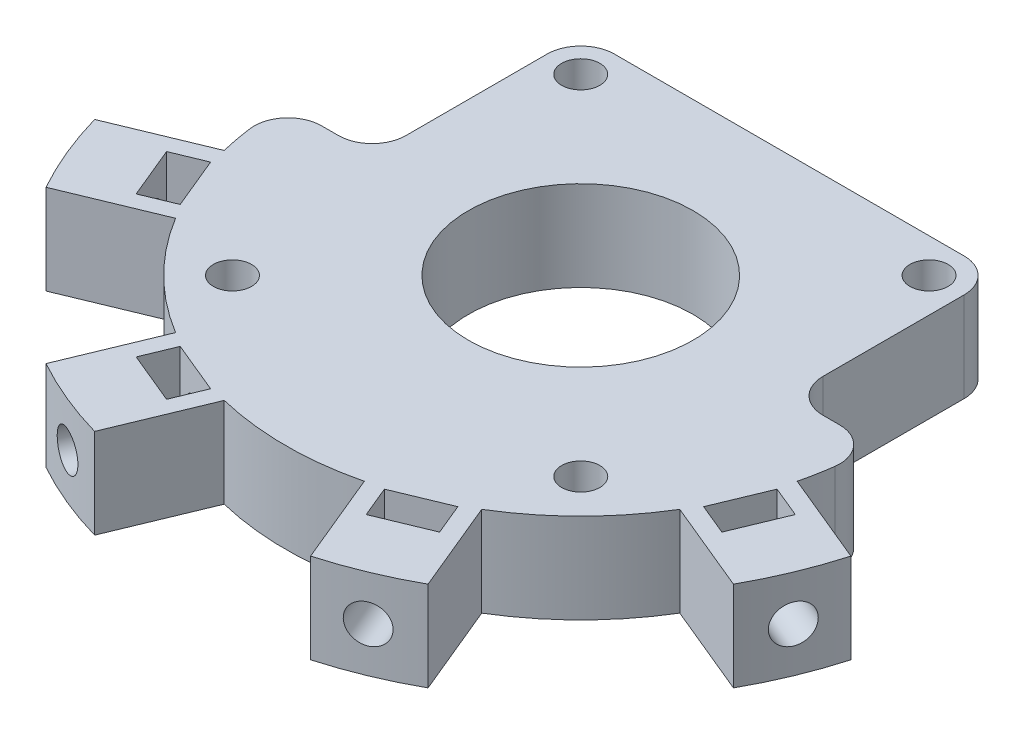
from build123d import *

# Parameters (mm, degrees)
SALIENTE_EXTRUIR1_DEPTH = 8
CROQUIS3_R              = 1.7
CORTAR_EXTRUIR1_DEPTH   = 10
CORTAR_EXTRUIR2_DEPTH   = 7
MATRIZC1_COUNT          = 4
MATRIZC1_ANGLE          = 135
CROQUIS5_R              = 10
CROQUIS5_R_2            = 1.7
CORTAR_EXTRUIR3_DEPTH   = 8
CORTAR_EXTRUIR4_DEPTH   = 8
REDONDEO1_R             = 3


with BuildPart() as part:
    # Croquis1 → Saliente-Extruir1 (new body)
    with BuildSketch(Plane(origin=(0, 0, 0), x_dir=(1, 0, 0), z_dir=(0, 1, 0))):
        with BuildLine():
            Line((-33.65465082, -9.610644005), (-25.499354444, -6.232609641))
            ThreePointArc((-25.499354444, -6.232609641), (0, 26.25), (25.499354444, -6.232609641))
            Line((25.499354444, -6.232609641), (33.65465082, -9.610644005))
            ThreePointArc((33.65465082, -9.610644005), (32.335783638, -13.393920133), (30.593183361, -17.001680265))
            Line((30.593183361, -17.001680265), (22.437886985, -13.623645901))
            ThreePointArc((22.437886985, -13.623645901), (18.561553006, -18.561553006), (13.623645901, -22.437886985))
            Line((13.623645901, -22.437886985), (17.001680265, -30.593183361))
            ThreePointArc((17.001680265, -30.593183361), (13.393920133, -32.335783638), (9.610644005, -33.65465082))
            Line((9.610644005, -33.65465082), (6.232609641, -25.499354444))
            ThreePointArc((6.232609641, -25.499354444), (0, -26.25), (-6.232609641, -25.499354444))
            Line((-6.232609641, -25.499354444), (-9.610644005, -33.65465082))
            ThreePointArc((-9.610644005, -33.65465082), (-13.393920133, -32.335783638), (-17.001680265, -30.593183361))
            Line((-17.001680265, -30.593183361), (-13.623645901, -22.437886985))
            ThreePointArc((-13.623645901, -22.437886985), (-18.561553006, -18.561553006), (-22.437886985, -13.623645901))
            Line((-22.437886985, -13.623645901), (-30.593183361, -17.001680265))
            ThreePointArc((-30.593183361, -17.001680265), (-32.335783638, -13.393920133), (-33.65465082, -9.610644005))
        make_face()
    extrude(amount=SALIENTE_EXTRUIR1_DEPTH)

    # Croquis3 → Cortar-Extruir1 (cut)
    with BuildSketch(Plane(origin=(-32.335783638, 0, 13.393920133), x_dir=(0.382683432, 0, 0.923879533), z_dir=(-0.923879533, 0, 0.382683432))):
        with Locations((0, 4)):
            Circle(CROQUIS3_R)
    cortar_extruir1 = extrude(amount=-CORTAR_EXTRUIR1_DEPTH, mode=Mode.SUBTRACT)

    # Croquis4 → Cortar-Extruir2 (cut)
    with BuildSketch(Plane(origin=(0, 8, 0), x_dir=(1, 0, 0), z_dir=(0, 1, 0))):
        Polygon((-27.980184907, -8.883791565), (-26.066767745, -13.503189228), (-23.295129148, -12.355138931), (-25.208546309, -7.735741268), align=None)
    cortar_extruir2 = extrude(amount=-CORTAR_EXTRUIR2_DEPTH, mode=Mode.SUBTRACT)

    # MatrizC1: Cortar-Extruir1, Cortar-Extruir2 ×4 about axis
    matrizc1_axis = Axis((0, 0, 0), (0, 1, 0))
    for i in range(1, MATRIZC1_COUNT):
        add(cortar_extruir1.rotate(matrizc1_axis, i * MATRIZC1_ANGLE / (MATRIZC1_COUNT - 1)), mode=Mode.SUBTRACT)
        add(cortar_extruir2.rotate(matrizc1_axis, i * MATRIZC1_ANGLE / (MATRIZC1_COUNT - 1)), mode=Mode.SUBTRACT)

    # Croquis5 → Cortar-Extruir3 (cut)
    with BuildSketch(Plane(origin=(0, 8, 0), x_dir=(1, 0, 0), z_dir=(0, 1, 0))):
        Circle(CROQUIS5_R)
        with Locations((-15.5, 15.5)):
            Circle(CROQUIS5_R_2)
        with Locations((15.5, 15.5)):
            Circle(CROQUIS5_R_2)
        with Locations((15.5, -15.5)):
            Circle(CROQUIS5_R_2)
        with Locations((-15.5, -15.5)):
            Circle(CROQUIS5_R_2)
    extrude(amount=-CORTAR_EXTRUIR3_DEPTH, mode=Mode.SUBTRACT)

    # Croquis6 → Cortar-Extruir4 (cut)
    with BuildSketch(Plane(origin=(0, 8, 0), x_dir=(1, 0, 0), z_dir=(0, 1, 0))):
        Polygon((18.561553006, 18.561553006), (-18.561553006, 18.561553006), (-18.561553006, 0), (-26.25, 0), (-26.25, 31.288102552), (26.25, 31.288102552), (26.25, 0), (18.561553006, 0), align=None)
    extrude(amount=-CORTAR_EXTRUIR4_DEPTH, mode=Mode.SUBTRACT)

    # Redondeo1
    redondeo1_edges = [part.edges().sort_by_distance(p)[0] for p in [
        (-18.561553006, 4, -18.561553006),
        (-18.561553006, 4, 0),
        (-26.25, 4, 0),
        (26.25, 4, 0),
        (18.561553006, 4, 0),
        (18.561553006, 4, -18.561553006),
    ]]
    fillet(redondeo1_edges, radius=REDONDEO1_R)


solid = part.part
